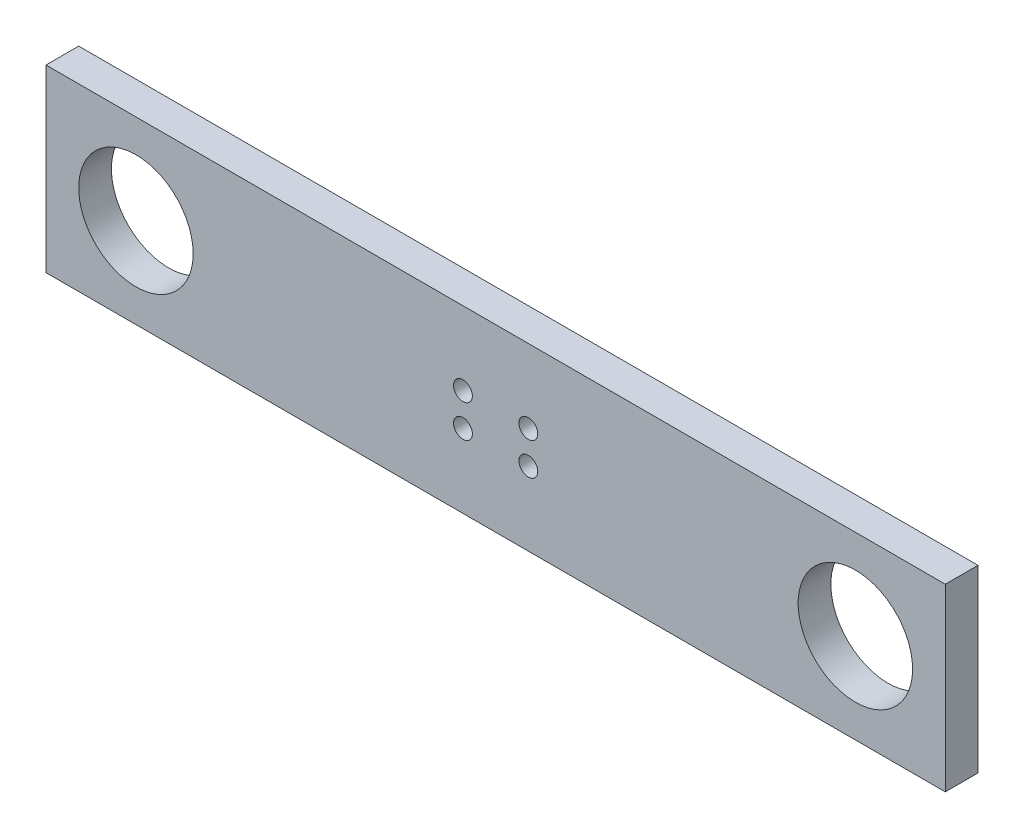
from build123d import *

# Parameters (mm, degrees)
SKETCH1_W           = 174.625
SKETCH1_H           = 34.925
SKETCH1_R           = 11.1125
SKETCH1_R_2         = 1.8288
BOSS_EXTRUDE1_DEPTH = 6.35


with BuildPart() as part:
    # Sketch1 → Boss-Extrude1 (new body)
    with BuildSketch(Plane.XY):
        Rectangle(SKETCH1_W, SKETCH1_H)
        with Locations((-69.85, 0)):
            Circle(SKETCH1_R, mode=Mode.SUBTRACT)
        with Locations((69.85, 0)):
            Circle(SKETCH1_R, mode=Mode.SUBTRACT)
        with Locations((-6.35, 3.175)):
            Circle(SKETCH1_R_2, mode=Mode.SUBTRACT)
        with Locations((6.35, 3.175)):
            Circle(SKETCH1_R_2, mode=Mode.SUBTRACT)
        with Locations((-6.35, -3.175)):
            Circle(SKETCH1_R_2, mode=Mode.SUBTRACT)
        with Locations((6.35, -3.175)):
            Circle(SKETCH1_R_2, mode=Mode.SUBTRACT)
    extrude(amount=BOSS_EXTRUDE1_DEPTH)


solid = part.part
